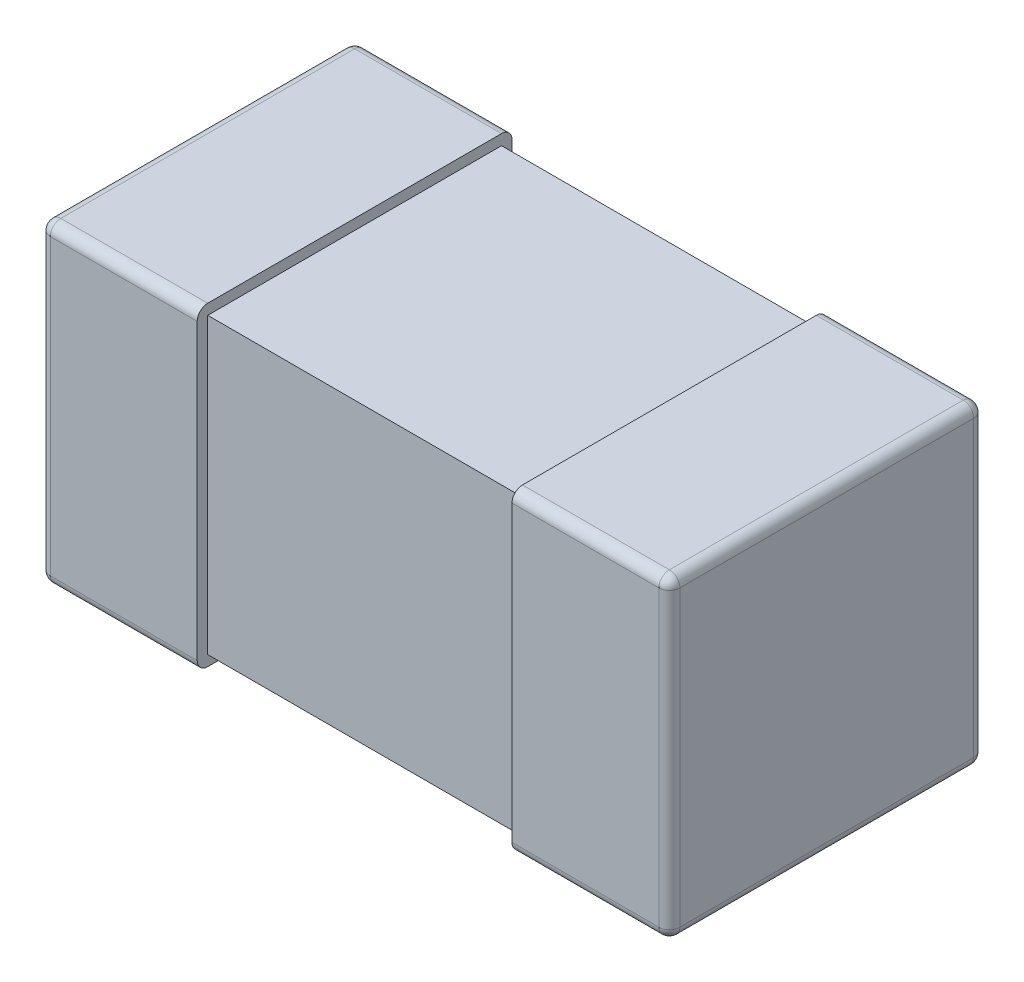
from build123d import *

# Parameters (mm, degrees)
SKETCH1_W            = 0.15
SKETCH1_H            = 0.3
THICKNESS_DEPTH      = 0.15
FILLET1_R            = 0.01
SKETCH2_W            = 0.28
SKETCH2_H            = 0.28
BOSS_EXTRUDE2_DEPTH  = 0.15
FILLET1_OF_MIRROR3_R = 0.01


with BuildPart() as part:
    # Sketch1 → THICKNESS (new body, symmetric)
    with BuildSketch(Plane(origin=(0, 0, 0), x_dir=(1, 0, 0), z_dir=(0, 1, 0))):
        with Locations((-0.225, 0)):
            Rectangle(SKETCH1_W, SKETCH1_H)
    thickness = extrude(amount=THICKNESS_DEPTH, both=True)

    # Fillet1
    fillet1_edges = [part.edges().sort_by_distance(p)[0] for p in [
        (-0.225, 0.15, -0.15),
        (-0.3, 0.15, 0),
        (-0.225, -0.15, -0.15),
        (-0.225, -0.15, 0.15),
        (-0.3, -0.15, 0),
        (-0.225, 0.15, 0.15),
        (-0.3, 0, -0.15),
        (-0.3, 0, 0.15),
    ]]
    fillet(fillet1_edges, radius=FILLET1_R)

    # Sketch2 → Boss-Extrude2 (add)
    with BuildSketch(Plane(origin=(0, 0, 0), x_dir=(0, 0, -1), z_dir=(1, 0, 0))):
        Rectangle(SKETCH2_W, SKETCH2_H)
    boss_extrude2 = extrude(amount=-BOSS_EXTRUDE2_DEPTH)

    # Mirror3: THICKNESS, Boss-Extrude2 across plane
    add(thickness.mirror(Plane(origin=(0, 0, 0), x_dir=(0, 0, 1), z_dir=(1, 0, 0))))
    add(boss_extrude2.mirror(Plane(origin=(0, 0, 0), x_dir=(0, 0, 1), z_dir=(1, 0, 0))))

    # Fillet1 of Mirror3
    fillet1_of_mirror3_edges = [part.edges().sort_by_distance(p)[0] for p in [
        (0.225, 0.15, -0.15),
        (0.3, 0.15, 0),
        (0.225, -0.15, -0.15),
        (0.225, -0.15, 0.15),
        (0.3, -0.15, 0),
        (0.225, 0.15, 0.15),
        (0.3, 0, -0.15),
        (0.3, 0, 0.15),
    ]]
    fillet(fillet1_of_mirror3_edges, radius=FILLET1_OF_MIRROR3_R)


solid = part.part
